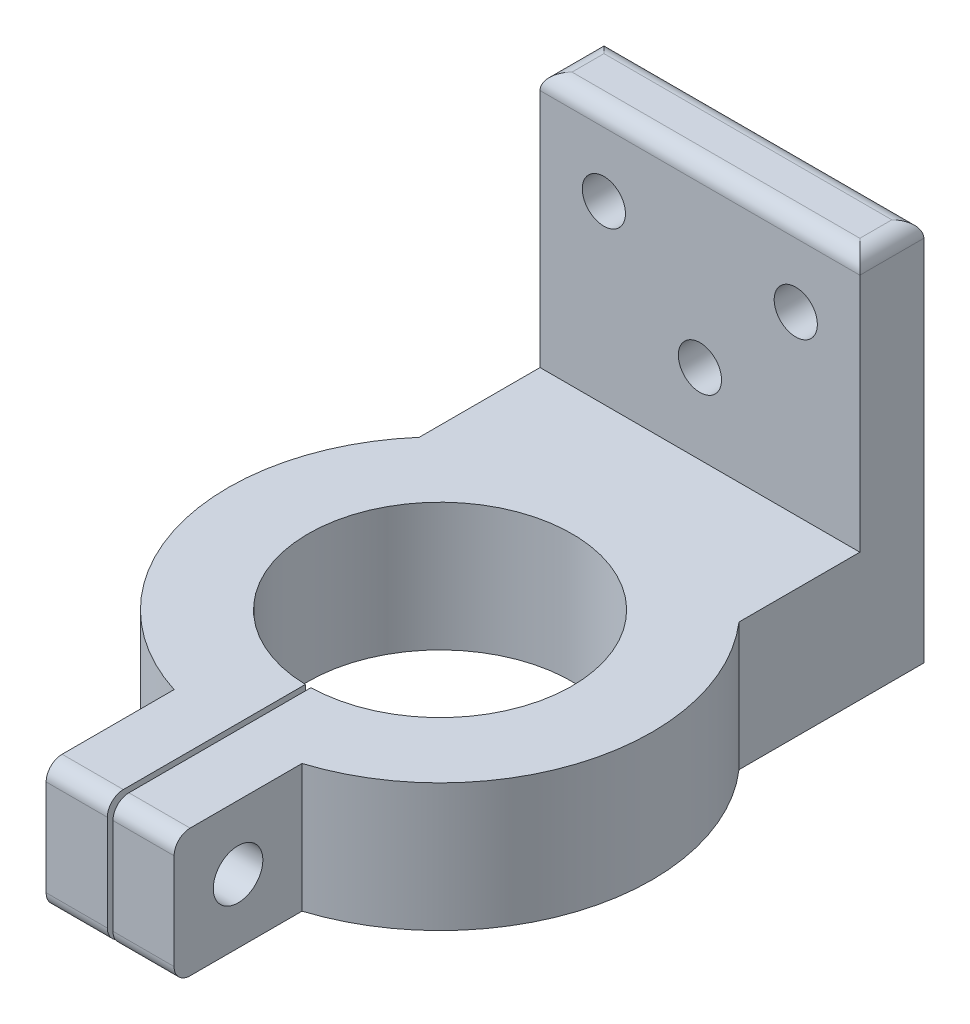
from build123d import *

# Parameters (mm, degrees)
SKETCH1_W           = 20
SKETCH1_H           = 24
SKETCH1_R           = 1.35
BOSS_EXTRUDE1_DEPTH = 4
SKETCH2_W           = 20
SKETCH2_H           = 8
BOSS_EXTRUDE2_DEPTH = 8
SKETCH3_R           = 8.25
BOSS_EXTRUDE3_DEPTH = 8
SKETCH4_W           = 0.35
SKETCH4_H           = 20.293623418
CUT_EXTRUDE1_DEPTH  = 8
SKETCH6_R           = 1.55
CUT_EXTRUDE2_DEPTH  = 8
FILLET1_R           = 1


with BuildPart() as part:
    # Sketch1 → Boss-Extrude1 (new body)
    with BuildSketch(Plane.XY):
        with Locations((0, -1)):
            Rectangle(SKETCH1_W, SKETCH1_H)
        with Locations((5.991996797, 6)):
            Circle(SKETCH1_R, mode=Mode.SUBTRACT)
        Circle(SKETCH1_R, mode=Mode.SUBTRACT)
        with Locations((-6.008003203, 6)):
            Circle(SKETCH1_R, mode=Mode.SUBTRACT)
    extrude(amount=BOSS_EXTRUDE1_DEPTH)

    # Sketch2 → Boss-Extrude2 (add)
    with BuildSketch(Plane.XY.offset(4)):
        with Locations((0, -9)):
            Rectangle(SKETCH2_W, SKETCH2_H)
    extrude(amount=BOSS_EXTRUDE2_DEPTH)

    # Sketch3 → Boss-Extrude3 (add)
    with BuildSketch(Plane.XZ.offset(13)):
        with BuildLine():
            Line((-4, 32.881805097), (-4, 40.881805097))
            Line((-4, 40.881805097), (4, 40.881805097))
            Line((4, 40.881805097), (4, 32.881805097))
            ThreePointArc((4, 32.881805097), (0, 7), (-4, 32.881805097))
        make_face()
        with Locations((0, 20.25)):
            Circle(SKETCH3_R, mode=Mode.SUBTRACT)
    extrude(amount=-BOSS_EXTRUDE3_DEPTH)

    # Sketch4 → Cut-Extrude1 (cut)
    with BuildSketch(Plane.XZ.offset(13)):
        with Locations((0, 38.64495544)):
            Rectangle(SKETCH4_W, SKETCH4_H)
    extrude(amount=-CUT_EXTRUDE1_DEPTH, mode=Mode.SUBTRACT)

    # Sketch6 → Cut-Extrude2 (cut)
    with BuildSketch(Plane(origin=(4, 0, 0), x_dir=(0, 0, -1), z_dir=(1, 0, 0))):
        with Locations((-36.881805097, -9)):
            Circle(SKETCH6_R)
    extrude(amount=-CUT_EXTRUDE2_DEPTH, mode=Mode.SUBTRACT)

    # Fillet1
    fillet1_edges = [part.edges().sort_by_distance(p)[0] for p in [
        (10, 11, 2),
        (0, 11, 4),
        (-10, 11, 2),
        (0, 11, 0),
        (-2.0875, -5, 40.881805097),
        (-2.0875, -13, 40.881805097),
        (2.0875, -13, 40.881805097),
        (2.0875, -5, 40.881805097),
    ]]
    fillet(fillet1_edges, radius=FILLET1_R)


solid = part.part
